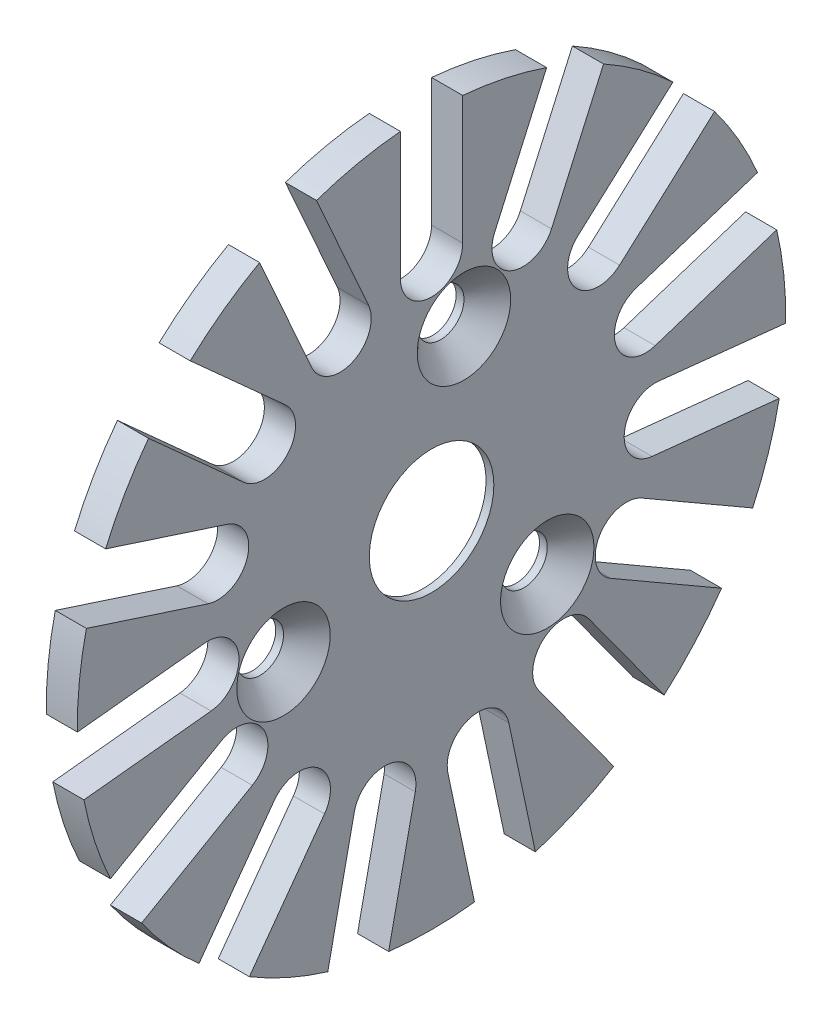
from build123d import *

# Parameters (mm, degrees)
SKETCH1_R                    = 22.75
BOSS_EXTRUDE1_DEPTH          = 2
CUT_EXTRUDE2_REACH           = 4
SKETCH3_R                    = 4
SKETCH2_R                    = 1.5
CUT_EXTRUDE1_DEPTH           = 2
CHAMFER1_SIZE                = 1.5
CIRPATTERN1_COUNT            = 3
CHAMFER1_OF_CIRPATTERN1_SIZE = 1.5
CUT_EXTRUDE3_DEPTH           = 2
CIRPATTERN2_COUNT            = 15
SKETCH5_R                    = 7
CUT_EXTRUDE4_DEPTH           = 1.5


with BuildPart() as part:
    # Sketch1 → Boss-Extrude1 (new body)
    with BuildSketch(Plane(origin=(0, 0, 0), x_dir=(0, 0, -1), z_dir=(1, 0, 0))):
        Circle(SKETCH1_R)
    extrude(amount=BOSS_EXTRUDE1_DEPTH)

    # Sketch3 → Cut-Extrude2 (cut, up to next)
    with BuildSketch(Plane(origin=(2, 0, 0), x_dir=(0, 0, -1), z_dir=(1, 0, 0)), mode=Mode.PRIVATE) as cut_extrude2_sk1:
        Circle(SKETCH3_R)
    cut_extrude2_tool1 = extrude(cut_extrude2_sk1.sketch, amount=-CUT_EXTRUDE2_REACH, mode=Mode.PRIVATE) & part.part
    add(cut_extrude2_tool1.solids().sort_by_distance((2, 0, 0))[0], mode=Mode.SUBTRACT)

    # Sketch2 → Cut-Extrude1 (cut)
    with BuildSketch(Plane(origin=(2, 0, 0), x_dir=(0, 0, -1), z_dir=(1, 0, 0))):
        with Locations((2.079116908, 9.781476007)):
            Circle(SKETCH2_R)
    cut_extrude1 = extrude(amount=-CUT_EXTRUDE1_DEPTH, mode=Mode.SUBTRACT)

    # Chamfer1
    chamfer1_edges = [part.edges().sort_by_distance(p)[0] for p in [
        (2, 9.781476007, -0.579116908),
    ]]
    chamfer(chamfer1_edges, length=CHAMFER1_SIZE)

    # CirPattern1: Cut-Extrude1 ×3 about axis
    cirpattern1_axis = Axis((0, 0, 0), (1, 0, 0))
    for i in range(1, CIRPATTERN1_COUNT):
        add(cut_extrude1.rotate(cirpattern1_axis, i * 360 / CIRPATTERN1_COUNT), mode=Mode.SUBTRACT)

    # Chamfer1 of CirPattern1
    chamfer1_of_cirpattern1_edges = [part.edges().sort_by_distance(p)[0] for p in [
        (2, -4.389208049, 8.760565163),
        (2, -5.392267958, -8.181448255),
    ]]
    chamfer(chamfer1_of_cirpattern1_edges, length=CHAMFER1_OF_CIRPATTERN1_SIZE)

    # Sketch4 → Cut-Extrude3 (cut)
    with BuildSketch(Plane(origin=(2, 0, 0), x_dir=(0, 0, -1), z_dir=(1, 0, 0))):
        with BuildLine():
            Line((-2, 22.75), (-2, 14.45))
            ThreePointArc((-2, 14.45), (0, 12.45), (2, 14.45))
            Line((2, 14.45), (2, 22.75))
            Line((2, 22.75), (-2, 22.75))
        make_face()
    cut_extrude3 = extrude(amount=-CUT_EXTRUDE3_DEPTH, mode=Mode.SUBTRACT)

    # CirPattern2: Cut-Extrude3 ×15 about axis
    cirpattern2_axis = Axis((0, 0, 0), (1, 0, 0))
    for i in range(1, CIRPATTERN2_COUNT):
        add(cut_extrude3.rotate(cirpattern2_axis, i * 360 / CIRPATTERN2_COUNT), mode=Mode.SUBTRACT)

    # Sketch5 → Cut-Extrude4 (cut)
    with BuildSketch(Plane.ZY):
        Circle(SKETCH5_R)
    extrude(amount=-CUT_EXTRUDE4_DEPTH, mode=Mode.SUBTRACT)


solid = part.part
